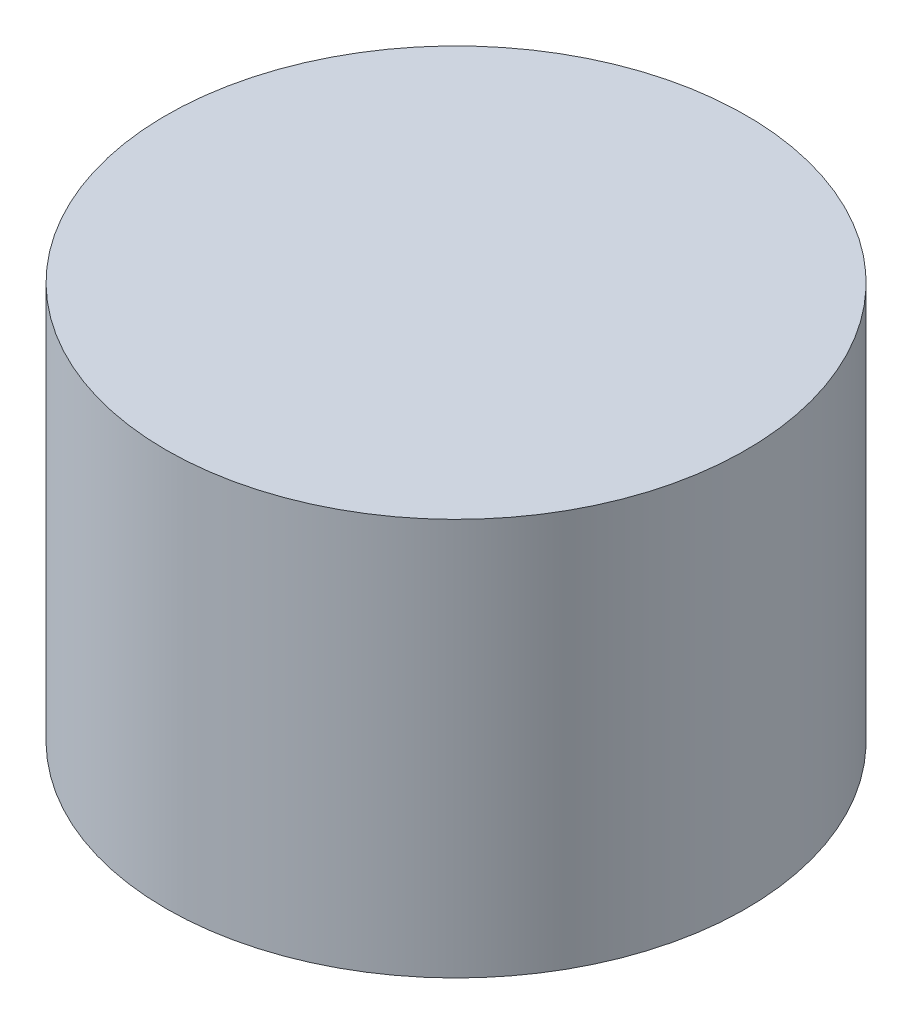
from build123d import *

# Parameters (mm, degrees)
SKETCH1_R           = 0.365
BOSS_EXTRUDE1_DEPTH = 0.5


with BuildPart() as part:
    # Sketch1 → Boss-Extrude1 (new body)
    with BuildSketch(Plane(origin=(0, 0, 0), x_dir=(1, 0, 0), z_dir=(0, 1, 0))):
        Circle(SKETCH1_R)
    extrude(amount=BOSS_EXTRUDE1_DEPTH)


solid = part.part
